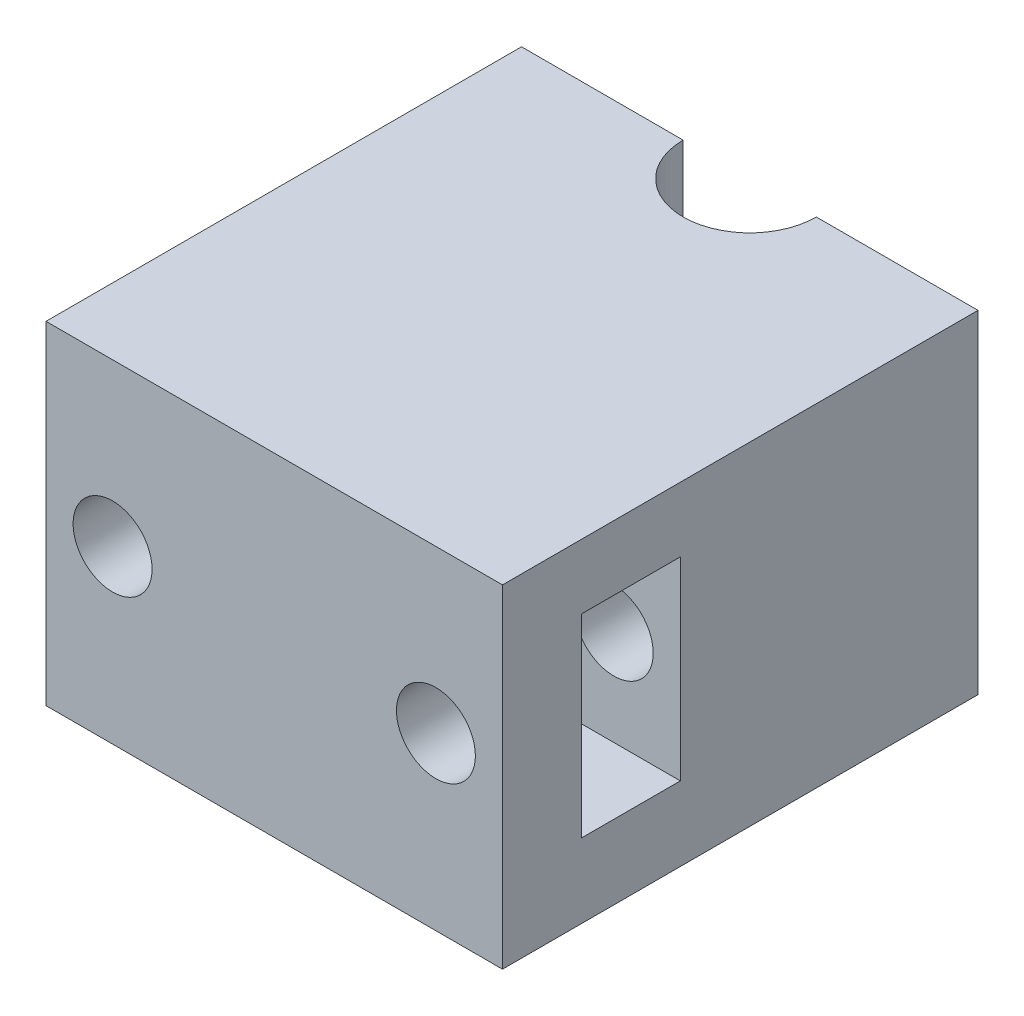
from build123d import *

# Parameters (mm, degrees)
SKETCH1_W               = 48
SKETCH1_H               = 50
BOSS_EXTRUDE1_DEPTH     = 70
SKETCH2_W               = 10.4
SKETCH2_H               = 20.4
CUT_EXTRUDE1_DEPTH      = 45
SKETCH3_R               = 4.15
CUT_EXTRUDE2_DEPTH      = 51
CUT_EXTRUDE3_DEPTH      = 1
CUT_EXTRUDE3_DEPTH_BACK = 71
SKETCH5_W               = 48
SKETCH5_H               = 50
CUT_EXTRUDE4_DEPTH      = 35


with BuildPart() as part:
    # Sketch1 → Boss-Extrude1 (new body)
    with BuildSketch(Plane(origin=(0, 0, 0), x_dir=(1, 0, 0), z_dir=(0, 1, 0))):
        Rectangle(SKETCH1_W, SKETCH1_H)
    extrude(amount=BOSS_EXTRUDE1_DEPTH)

    # Sketch2 → Cut-Extrude1 (cut)
    with BuildSketch(Plane(origin=(24, 0, 0), x_dir=(0, 0, -1), z_dir=(1, 0, 0))):
        with Locations((-11.5, 53)):
            Rectangle(SKETCH2_W, SKETCH2_H)
        with Locations((-11.5, 17)):
            Rectangle(SKETCH2_W, SKETCH2_H)
    extrude(amount=-CUT_EXTRUDE1_DEPTH, mode=Mode.SUBTRACT)

    # Sketch3 → Cut-Extrude2 (cut, through all)
    with BuildSketch(Plane.XY.offset(25)):
        with Locations((17, 53)):
            Circle(SKETCH3_R)
        with Locations((-17, 53)):
            Circle(SKETCH3_R)
        with Locations((-17, 17)):
            Circle(SKETCH3_R)
        with Locations((17, 17)):
            Circle(SKETCH3_R)
    extrude(amount=-CUT_EXTRUDE2_DEPTH, mode=Mode.SUBTRACT)

    # Sketch4 → Cut-Extrude3 (cut, two sides)
    with BuildSketch(Plane(origin=(0, 70, 0), x_dir=(1, 0, 0), z_dir=(0, 1, 0))) as cut_extrude3_sk:
        with BuildLine():
            Line((-7, 152.660528641), (-7, 25))
            ThreePointArc((-7, 25), (0, 18), (7, 25))
            Line((7, 25), (7, 152.660528641))
            Line((7, 152.660528641), (7, 407.981585922))
            Line((7, 407.981585922), (-7, 407.981585922))
            Line((-7, 407.981585922), (-7, 152.660528641))
        make_face()
    extrude(amount=CUT_EXTRUDE3_DEPTH, mode=Mode.SUBTRACT)
    extrude(cut_extrude3_sk.sketch, amount=-CUT_EXTRUDE3_DEPTH_BACK, mode=Mode.SUBTRACT)

    # Sketch5 → Cut-Extrude4 (cut)
    with BuildSketch(Plane.XZ):
        Rectangle(SKETCH5_W, SKETCH5_H)
    extrude(amount=-CUT_EXTRUDE4_DEPTH, mode=Mode.SUBTRACT)


solid = part.part
